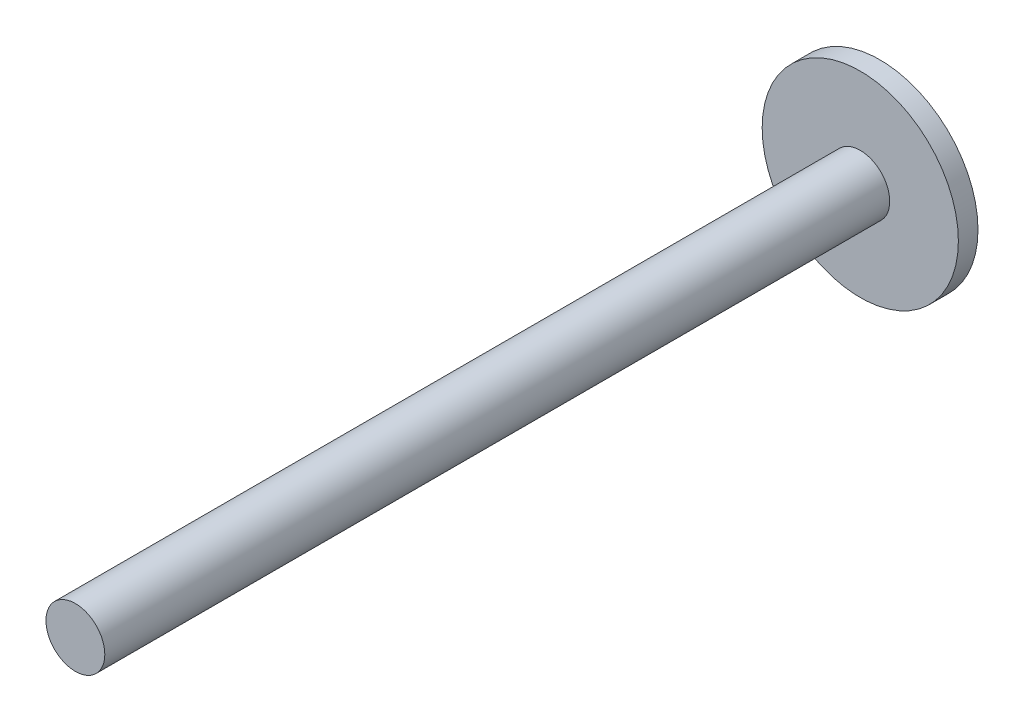
from build123d import *

# Parameters (mm, degrees)
SKETCH1_R           = 450
BOSS_EXTRUDE1_DEPTH = 12000
SKETCH2_R           = 1500
BOSS_EXTRUDE2_DEPTH = 300


with BuildPart() as part:
    # Sketch1 → Boss-Extrude1 (new body)
    with BuildSketch(Plane.XY):
        Circle(SKETCH1_R)
    extrude(amount=BOSS_EXTRUDE1_DEPTH)

    # Sketch2 → Boss-Extrude2 (add)
    with BuildSketch(Plane(origin=(0, 0, 0), x_dir=(-1, 0, 0), z_dir=(0, 0, -1))):
        Circle(SKETCH2_R)
    extrude(amount=BOSS_EXTRUDE2_DEPTH)


solid = part.part
